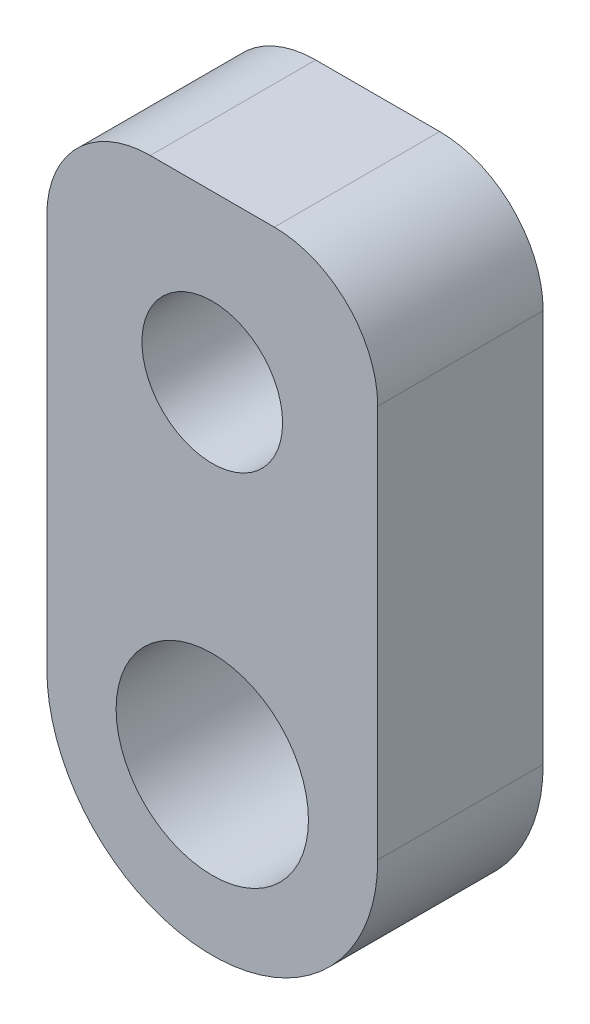
from build123d import *

# Parameters (mm, degrees)
SKETCH1_R           = 4
BOSS_EXTRUDE1_DEPTH = 4
SKETCH3_W           = 8
SKETCH3_H           = 12
BOSS_EXTRUDE2_DEPTH = 4
SKETCH2_R           = 2.325
CUT_EXTRUDE2_DEPTH  = 5
SKETCH4_R           = 1.7
CUT_EXTRUDE3_DEPTH  = 4
FILLET1_R           = 2.5


with BuildPart() as part:
    # Sketch1 → Boss-Extrude1 (new body)
    with BuildSketch(Plane.XY):
        Circle(SKETCH1_R)
    extrude(amount=BOSS_EXTRUDE1_DEPTH)

    # Sketch3 → Boss-Extrude2 (add)
    with BuildSketch(Plane.XY):
        with Locations((0, 6)):
            Rectangle(SKETCH3_W, SKETCH3_H)
    extrude(amount=BOSS_EXTRUDE2_DEPTH)

    # Sketch2 → Cut-Extrude2 (cut, through all)
    with BuildSketch(Plane.XY):
        Circle(SKETCH2_R)
    extrude(amount=CUT_EXTRUDE2_DEPTH, mode=Mode.SUBTRACT)

    # Sketch4 → Cut-Extrude3 (cut)
    with BuildSketch(Plane.XY):
        with Locations((0, 8)):
            Circle(SKETCH4_R)
    extrude(amount=CUT_EXTRUDE3_DEPTH, mode=Mode.SUBTRACT)

    # Fillet1
    fillet1_edges = [part.edges().sort_by_distance(p)[0] for p in [
        (4, 12, 2),
        (-4, 12, 2),
    ]]
    fillet(fillet1_edges, radius=FILLET1_R)


solid = part.part
